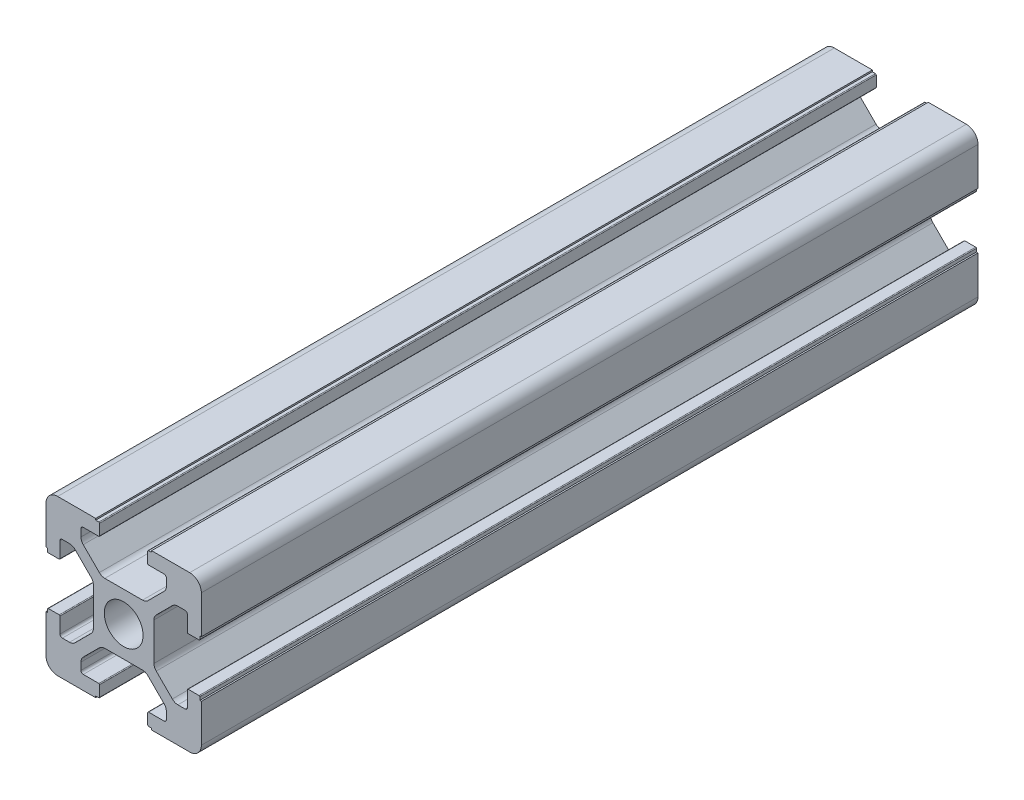
from build123d import *

# Parameters (mm, degrees)
SKETCH_1_R      = 2.5
EXTRUDE_1_DEPTH = 100
FILLET_1_R      = 1.5


with BuildPart() as part:
    # 草图1 → 凸台-拉伸1 (new body)
    with BuildSketch(Plane.XY):
        with BuildLine():
            Line((20, 13.6), (20, 20))
            Line((20, 20), (13.6, 20))
            Line((13.6, 20), (13.6, 19.8))
            Line((13.6, 19.8), (13.2, 19.8))
            ThreePointArc((13.2, 19.8), (13.129289322, 19.770710678), (13.1, 19.7))
            Line((13.1, 19.7), (13.1, 18.3))
            ThreePointArc((13.1, 18.3), (13.129289322, 18.229289322), (13.2, 18.2))
            Line((13.2, 18.2), (15.2, 18.2))
            ThreePointArc((15.2, 18.2), (15.412132034, 18.112132034), (15.5, 17.9))
            Line((15.5, 17.9), (15.5, 16.974873734))
            ThreePointArc((15.5, 16.974873734), (15.423879533, 16.592190302), (15.207106781, 16.267766953))
            Line((15.207106781, 16.267766953), (13.132233047, 14.192893219))
            ThreePointArc((13.132233047, 14.192893219), (12.807809698, 13.976120467), (12.425126266, 13.9))
            Line((12.425126266, 13.9), (7.574873734, 13.9))
            ThreePointArc((7.574873734, 13.9), (7.192190302, 13.976120467), (6.867766953, 14.192893219))
            Line((6.867766953, 14.192893219), (4.792893219, 16.267766953))
            ThreePointArc((4.792893219, 16.267766953), (4.576120467, 16.592190302), (4.5, 16.974873734))
            Line((4.5, 16.974873734), (4.5, 17.9))
            ThreePointArc((4.5, 17.9), (4.587867966, 18.112132034), (4.8, 18.2))
            Line((4.8, 18.2), (6.8, 18.2))
            ThreePointArc((6.8, 18.2), (6.870710678, 18.229289322), (6.9, 18.3))
            Line((6.9, 18.3), (6.9, 19.7))
            ThreePointArc((6.9, 19.7), (6.870710678, 19.770710678), (6.8, 19.8))
            Line((6.8, 19.8), (6.4, 19.8))
            Line((6.4, 19.8), (6.4, 20))
            Line((6.4, 20), (0, 20))
            Line((0, 20), (0, 13.6))
            Line((0, 13.6), (0.2, 13.6))
            Line((0.2, 13.6), (0.2, 13.2))
            ThreePointArc((0.2, 13.2), (0.229289322, 13.129289322), (0.3, 13.1))
            Line((0.3, 13.1), (1.7, 13.1))
            ThreePointArc((1.7, 13.1), (1.770710678, 13.129289322), (1.8, 13.2))
            Line((1.8, 13.2), (1.8, 15.2))
            ThreePointArc((1.8, 15.2), (1.887867966, 15.412132034), (2.1, 15.5))
            Line((2.1, 15.5), (3.025126266, 15.5))
            ThreePointArc((3.025126266, 15.5), (3.407809698, 15.423879533), (3.732233047, 15.207106781))
            Line((3.732233047, 15.207106781), (5.807106781, 13.132233047))
            ThreePointArc((5.807106781, 13.132233047), (6.023879533, 12.807809698), (6.1, 12.425126266))
            Line((6.1, 12.425126266), (6.1, 7.574873734))
            ThreePointArc((6.1, 7.574873734), (6.023879533, 7.192190302), (5.807106781, 6.867766953))
            Line((5.807106781, 6.867766953), (3.732233047, 4.792893219))
            ThreePointArc((3.732233047, 4.792893219), (3.407809698, 4.576120467), (3.025126266, 4.5))
            Line((3.025126266, 4.5), (2.1, 4.5))
            ThreePointArc((2.1, 4.5), (1.887867966, 4.587867966), (1.8, 4.8))
            Line((1.8, 4.8), (1.8, 6.8))
            ThreePointArc((1.8, 6.8), (1.770710678, 6.870710678), (1.7, 6.9))
            Line((1.7, 6.9), (0.3, 6.9))
            ThreePointArc((0.3, 6.9), (0.229289322, 6.870710678), (0.2, 6.8))
            Line((0.2, 6.8), (0.2, 6.4))
            Line((0.2, 6.4), (0, 6.4))
            Line((0, 6.4), (0, 0))
            Line((0, 0), (6.4, 0))
            Line((6.4, 0), (6.4, 0.2))
            Line((6.4, 0.2), (6.8, 0.2))
            ThreePointArc((6.8, 0.2), (6.870710678, 0.229289322), (6.9, 0.3))
            Line((6.9, 0.3), (6.9, 1.7))
            ThreePointArc((6.9, 1.7), (6.870710678, 1.770710678), (6.8, 1.8))
            Line((6.8, 1.8), (4.8, 1.8))
            ThreePointArc((4.8, 1.8), (4.587867966, 1.887867966), (4.5, 2.1))
            Line((4.5, 2.1), (4.5, 3.025126266))
            ThreePointArc((4.5, 3.025126266), (4.576120467, 3.407809698), (4.792893219, 3.732233047))
            Line((4.792893219, 3.732233047), (6.867766953, 5.807106781))
            ThreePointArc((6.867766953, 5.807106781), (7.192190302, 6.023879533), (7.574873734, 6.1))
            Line((7.574873734, 6.1), (12.425126266, 6.1))
            ThreePointArc((12.425126266, 6.1), (12.807809698, 6.023879533), (13.132233047, 5.807106781))
            Line((13.132233047, 5.807106781), (15.207106781, 3.732233047))
            ThreePointArc((15.207106781, 3.732233047), (15.423879533, 3.407809698), (15.5, 3.025126266))
            Line((15.5, 3.025126266), (15.5, 2.1))
            ThreePointArc((15.5, 2.1), (15.412132034, 1.887867966), (15.2, 1.8))
            Line((15.2, 1.8), (13.2, 1.8))
            ThreePointArc((13.2, 1.8), (13.129289322, 1.770710678), (13.1, 1.7))
            Line((13.1, 1.7), (13.1, 0.3))
            ThreePointArc((13.1, 0.3), (13.129289322, 0.229289322), (13.2, 0.2))
            Line((13.2, 0.2), (13.6, 0.2))
            Line((13.6, 0.2), (13.6, 0))
            Line((13.6, 0), (20, 0))
            Line((20, 0), (20, 6.4))
            Line((20, 6.4), (19.8, 6.4))
            Line((19.8, 6.4), (19.8, 6.8))
            ThreePointArc((19.8, 6.8), (19.770710678, 6.870710678), (19.7, 6.9))
            Line((19.7, 6.9), (18.3, 6.9))
            ThreePointArc((18.3, 6.9), (18.229289322, 6.870710678), (18.2, 6.8))
            Line((18.2, 6.8), (18.2, 4.8))
            ThreePointArc((18.2, 4.8), (18.112132034, 4.587867966), (17.9, 4.5))
            Line((17.9, 4.5), (16.974873734, 4.5))
            ThreePointArc((16.974873734, 4.5), (16.592190302, 4.576120467), (16.267766953, 4.792893219))
            Line((16.267766953, 4.792893219), (14.192893219, 6.867766953))
            ThreePointArc((14.192893219, 6.867766953), (13.976120467, 7.192190302), (13.9, 7.574873734))
            Line((13.9, 7.574873734), (13.9, 12.425126266))
            ThreePointArc((13.9, 12.425126266), (13.976120467, 12.807809698), (14.192893219, 13.132233047))
            Line((14.192893219, 13.132233047), (16.267766953, 15.207106781))
            ThreePointArc((16.267766953, 15.207106781), (16.592190302, 15.423879533), (16.974873734, 15.5))
            Line((16.974873734, 15.5), (17.9, 15.5))
            ThreePointArc((17.9, 15.5), (18.112132034, 15.412132034), (18.2, 15.2))
            Line((18.2, 15.2), (18.2, 13.2))
            ThreePointArc((18.2, 13.2), (18.229289322, 13.129289322), (18.3, 13.1))
            Line((18.3, 13.1), (19.7, 13.1))
            ThreePointArc((19.7, 13.1), (19.770710678, 13.129289322), (19.8, 13.2))
            Line((19.8, 13.2), (19.8, 13.6))
            Line((19.8, 13.6), (20, 13.6))
        make_face()
        with Locations((10, 10)):
            Circle(SKETCH_1_R, mode=Mode.SUBTRACT)
    extrude(amount=EXTRUDE_1_DEPTH)

    # 圆角1
    fillet_1_edges = [part.edges().sort_by_distance(p)[0] for p in [
        (0, 0, 50),
        (0, 20, 50),
        (20, 20, 50),
        (20, 0, 50),
    ]]
    fillet(fillet_1_edges, radius=FILLET_1_R)


solid = part.part
